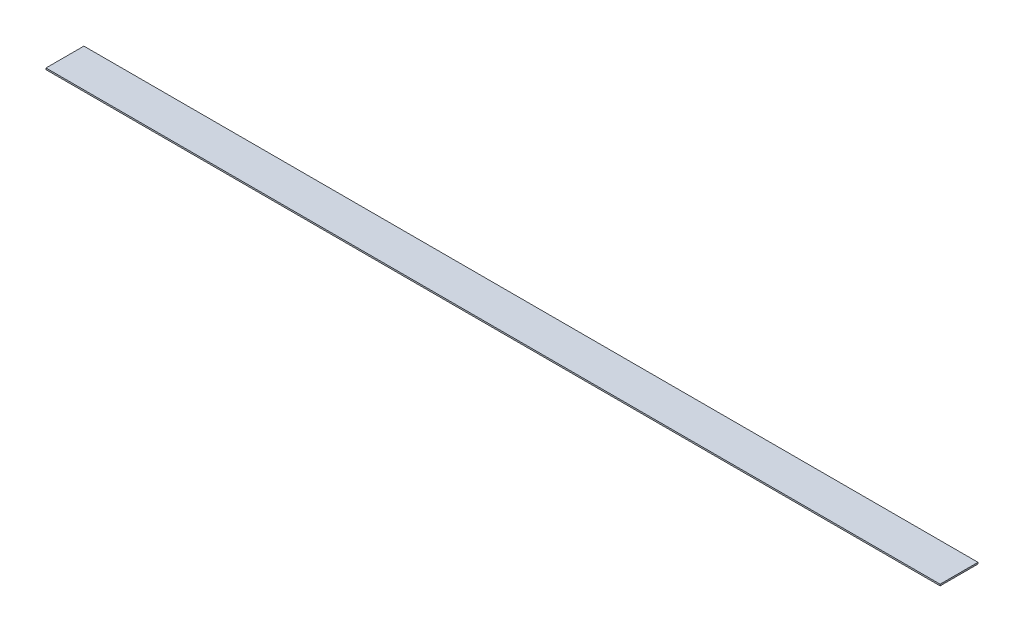
from build123d import *

# Parameters (mm, degrees)
SKETCH1_W           = 590
SKETCH1_H           = 25
BOSS_EXTRUDE1_DEPTH = 1


with BuildPart() as part:
    # Sketch1 → Boss-Extrude1 (new body)
    with BuildSketch(Plane(origin=(0, 0, 0), x_dir=(1, 0, 0), z_dir=(0, 1, 0))):
        Rectangle(SKETCH1_W, SKETCH1_H)
    extrude(amount=BOSS_EXTRUDE1_DEPTH)


solid = part.part
